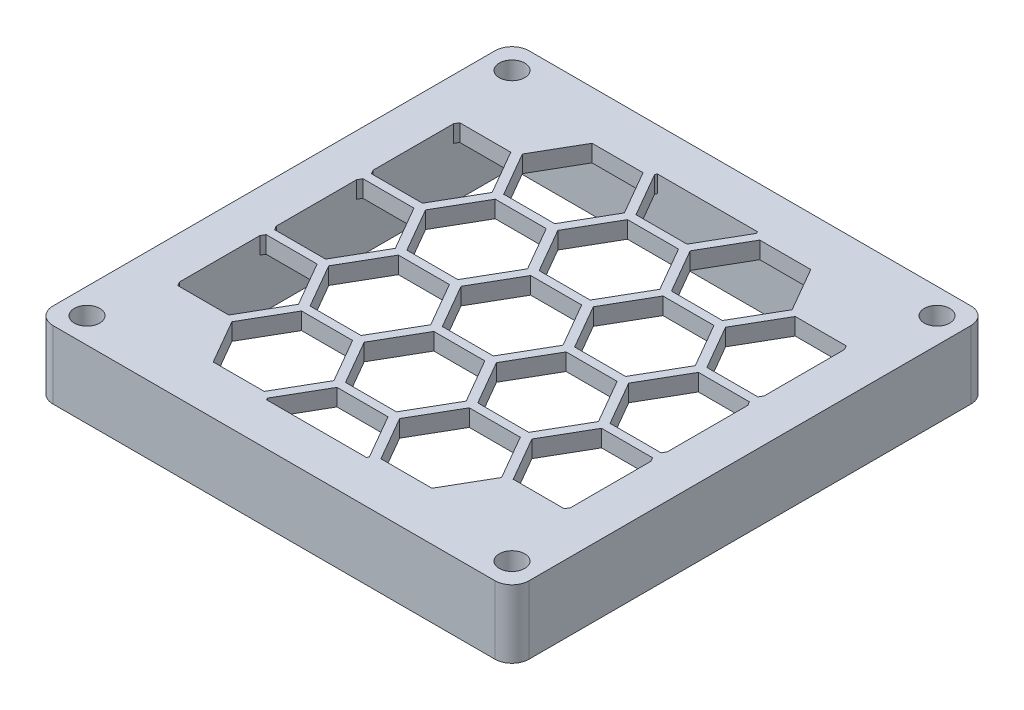
from build123d import *

# Parameters (mm, degrees)
SKETCH1_W               = 56
SKETCH1_H               = 56
SKETCH1_R               = 1.5
SKETCH1_W_2             = 46
SKETCH1_H_2             = 46
BOSS_EXTRUDE1_DEPTH     = 6
BOSS_EXTRUDE2_START     = 6
SKETCH1_2_W             = 56
SKETCH1_2_H             = 56
SKETCH1_2_R             = 1.5
BOSS_EXTRUDE2_DEPTH     = 2
CUT_EXTRUDE1_DEPTH      = 7
CUT_EXTRUDE1_DEPTH_BACK = 3
FILLET1_R               = 2


with BuildPart() as part:
    # Sketch1 → Boss-Extrude1 (new body)
    with BuildSketch(Plane(origin=(0, 0, 0), x_dir=(1, 0, 0), z_dir=(0, 1, 0))):
        Rectangle(SKETCH1_W, SKETCH1_H)
        with Locations((-25, 25)):
            Circle(SKETCH1_R, mode=Mode.SUBTRACT)
        with Locations((25, 25)):
            Circle(SKETCH1_R, mode=Mode.SUBTRACT)
        with Locations((25, -25)):
            Circle(SKETCH1_R, mode=Mode.SUBTRACT)
        with Locations((-25, -25)):
            Circle(SKETCH1_R, mode=Mode.SUBTRACT)
        Rectangle(SKETCH1_W_2, SKETCH1_H_2, mode=Mode.SUBTRACT)
    extrude(amount=BOSS_EXTRUDE1_DEPTH)

    # Sketch1_2 → Boss-Extrude2 (add)
    with BuildSketch(Plane(origin=(0, 0, 0), x_dir=(1, 0, 0), z_dir=(0, 1, 0)).offset(BOSS_EXTRUDE2_START)):
        Rectangle(SKETCH1_2_W, SKETCH1_2_H)
        with Locations((-25, 25)):
            Circle(SKETCH1_2_R, mode=Mode.SUBTRACT)
        with Locations((25, 25)):
            Circle(SKETCH1_2_R, mode=Mode.SUBTRACT)
        with Locations((25, -25)):
            Circle(SKETCH1_2_R, mode=Mode.SUBTRACT)
        with Locations((-25, -25)):
            Circle(SKETCH1_2_R, mode=Mode.SUBTRACT)
    extrude(amount=BOSS_EXTRUDE2_DEPTH)

    # Sketch2 → Cut-Extrude1 (cut, two sides)
    with BuildSketch(Plane.XZ.offset(-6)) as cut_extrude1_sk:
        Polygon((-22.732050808, 5.196152423), (-23, 4.732050808), (-23, -4.732050808), (-22.732050808, -5.196152423), (-16.732050808, -5.196152423), (-13.732050808, 0), (-16.732050808, 5.196152423), align=None)
        Polygon((-22.732050808, 16.588457268), (-23, 16.124355653), (-23, 6.660254038), (-22.732050808, 6.196152423), (-16.732050808, 6.196152423), (-13.732050808, 11.392304845), (-16.732050808, 16.588457268), align=None)
        Polygon((-3.866025404, 5.696152423), (-6.866025404, 10.892304845), (-12.866025404, 10.892304845), (-15.866025404, 5.696152423), (-12.866025404, 0.5), (-6.866025404, 0.5), align=None)
        Polygon((-12.866025404, 11.892304845), (-6.866025404, 11.892304845), (-3.866025404, 17.088457268), (-6.866025404, 22.284609691), (-12.866025404, 22.284609691), (-15.866025404, 17.088457268), align=None)
        Polygon((-6, 11.392304845), (-3, 6.196152423), (3, 6.196152423), (6, 11.392304845), (3, 16.588457268), (-3, 16.588457268), align=None)
        Polygon((6, 22.784609691), (5.875644347, 23), (-5.875644347, 23), (-6, 22.784609691), (-3, 17.588457268), (3, 17.588457268), align=None)
        Polygon((3.866025404, 17.088457268), (6.866025404, 11.892304845), (12.866025404, 11.892304845), (15.866025404, 17.088457268), (12.866025404, 22.284609691), (6.866025404, 22.284609691), align=None)
        Polygon((16.732050808, 6.196152423), (22.732050808, 6.196152423), (23, 6.660254038), (23, 16.124355653), (22.732050808, 16.588457268), (16.732050808, 16.588457268), (13.732050808, 11.392304845), align=None)
        Polygon((6.866025404, 0.5), (12.866025404, 0.5), (15.866025404, 5.696152423), (12.866025404, 10.892304845), (6.866025404, 10.892304845), (3.866025404, 5.696152423), align=None)
        Polygon((23, -4.732050808), (23, 4.732050808), (22.732050808, 5.196152423), (16.732050808, 5.196152423), (13.732050808, 0), (16.732050808, -5.196152423), (22.732050808, -5.196152423), align=None)
        Polygon((3.866025404, -5.696152423), (6.866025404, -10.892304845), (12.866025404, -10.892304845), (15.866025404, -5.696152423), (12.866025404, -0.5), (6.866025404, -0.5), align=None)
        Polygon((23, -16.124355653), (23, -6.660254038), (22.732050808, -6.196152423), (16.732050808, -6.196152423), (13.732050808, -11.392304845), (16.732050808, -16.588457268), (22.732050808, -16.588457268), align=None)
        Polygon((-6, 0), (-3, -5.196152423), (3, -5.196152423), (6, 0), (3, 5.196152423), (-3, 5.196152423), align=None)
        Polygon((-3, -6.196152423), (-6, -11.392304845), (-3, -16.588457268), (3, -16.588457268), (6, -11.392304845), (3, -6.196152423), align=None)
        Polygon((12.866025404, -11.892304845), (6.866025404, -11.892304845), (3.866025404, -17.088457268), (6.866025404, -22.284609691), (12.866025404, -22.284609691), (15.866025404, -17.088457268), align=None)
        Polygon((-5.875644347, -23), (5.875644347, -23), (6, -22.784609691), (3, -17.588457268), (-3, -17.588457268), (-6, -22.784609691), align=None)
        Polygon((-6.866025404, -0.5), (-12.866025404, -0.5), (-15.866025404, -5.696152423), (-12.866025404, -10.892304845), (-6.866025404, -10.892304845), (-3.866025404, -5.696152423), align=None)
        Polygon((-3.866025404, -17.088457268), (-6.866025404, -11.892304845), (-12.866025404, -11.892304845), (-15.866025404, -17.088457268), (-12.866025404, -22.284609691), (-6.866025404, -22.284609691), align=None)
        Polygon((-23, -6.660254038), (-23, -16.124355653), (-22.732050808, -16.588457268), (-16.732050808, -16.588457268), (-13.732050808, -11.392304845), (-16.732050808, -6.196152423), (-22.732050808, -6.196152423), align=None)
    extrude(amount=CUT_EXTRUDE1_DEPTH, mode=Mode.SUBTRACT)
    extrude(cut_extrude1_sk.sketch, amount=-CUT_EXTRUDE1_DEPTH_BACK, mode=Mode.SUBTRACT)

    # Fillet1
    fillet1_edges = [part.edges().sort_by_distance(p)[0] for p in [
        (28, 4, -28),
        (28, 4, 28),
        (-28, 4, 28),
        (-28, 4, -28),
    ]]
    fillet(fillet1_edges, radius=FILLET1_R)


solid = part.part
